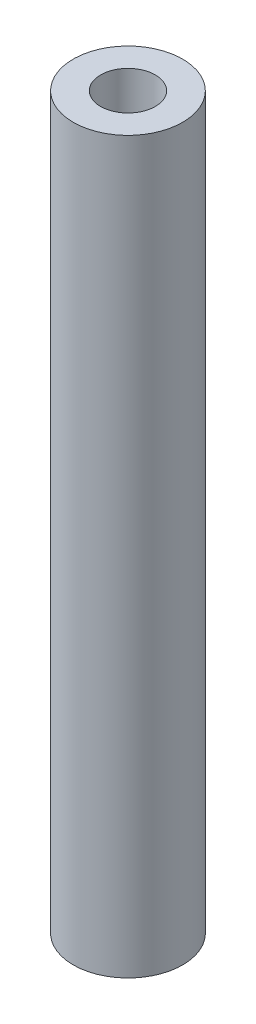
from build123d import *

# Parameters (mm, degrees)
SKETCH1_R           = 6
SKETCH1_R_2         = 1.5
BOSS_EXTRUDE1_DEPTH = 80
SKETCH2_R           = 3
CUT_EXTRUDE1_DEPTH  = 5


with BuildPart() as part:
    # Sketch1 → Boss-Extrude1 (new body)
    with BuildSketch(Plane(origin=(0, 0, 0), x_dir=(1, 0, 0), z_dir=(0, 1, 0))):
        Circle(SKETCH1_R)
        Circle(SKETCH1_R_2, mode=Mode.SUBTRACT)
    extrude(amount=BOSS_EXTRUDE1_DEPTH)

    # Sketch2 → Cut-Extrude1 (cut)
    with BuildSketch(Plane(origin=(0, 80, 0), x_dir=(1, 0, 0), z_dir=(0, 1, 0))):
        Circle(SKETCH2_R)
    extrude(amount=-CUT_EXTRUDE1_DEPTH, mode=Mode.SUBTRACT)


solid = part.part
